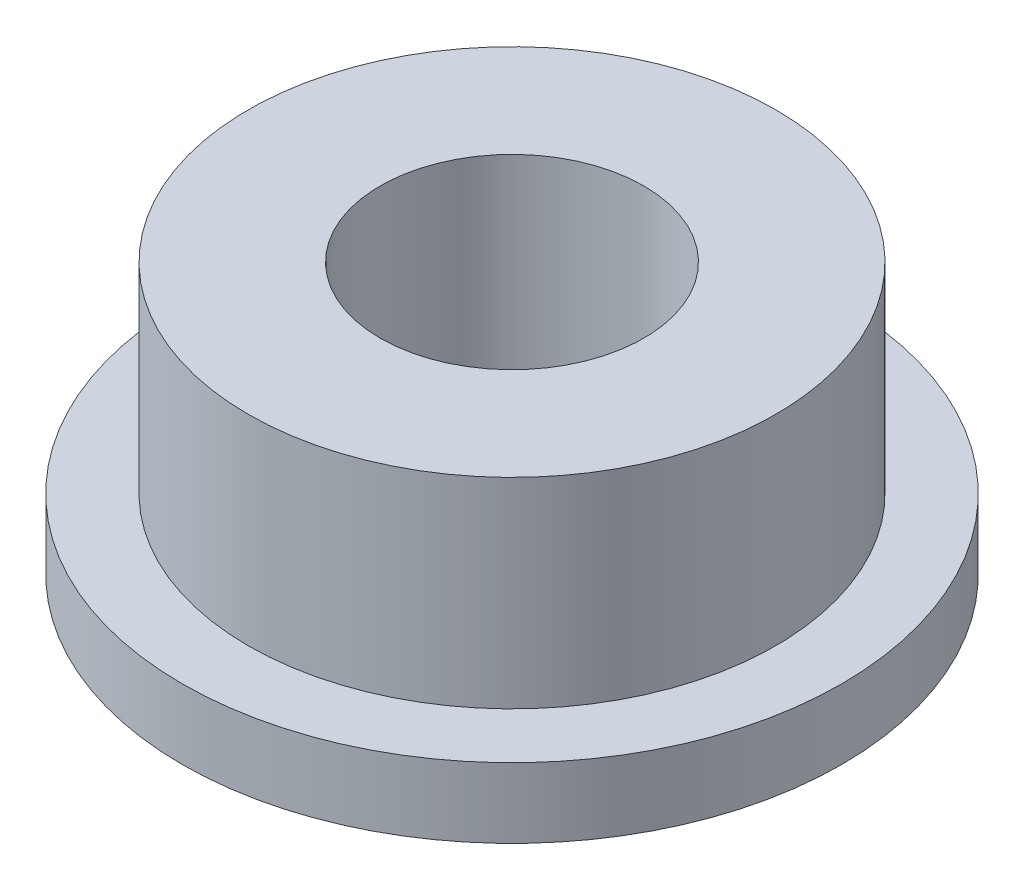
from build123d import *


with BuildPart() as part:
    # Sketch1 → Revolve1 (revolve)
    with BuildSketch(Plane.XY):
        Polygon((-5, 0), (-2, 0), (-2, 4.1), (-4, 4.1), (-4, 1.06), (-5, 1.06), align=None)
    revolve(axis=Axis((0, 0, 0), (0, 1, 0)))


solid = part.part
